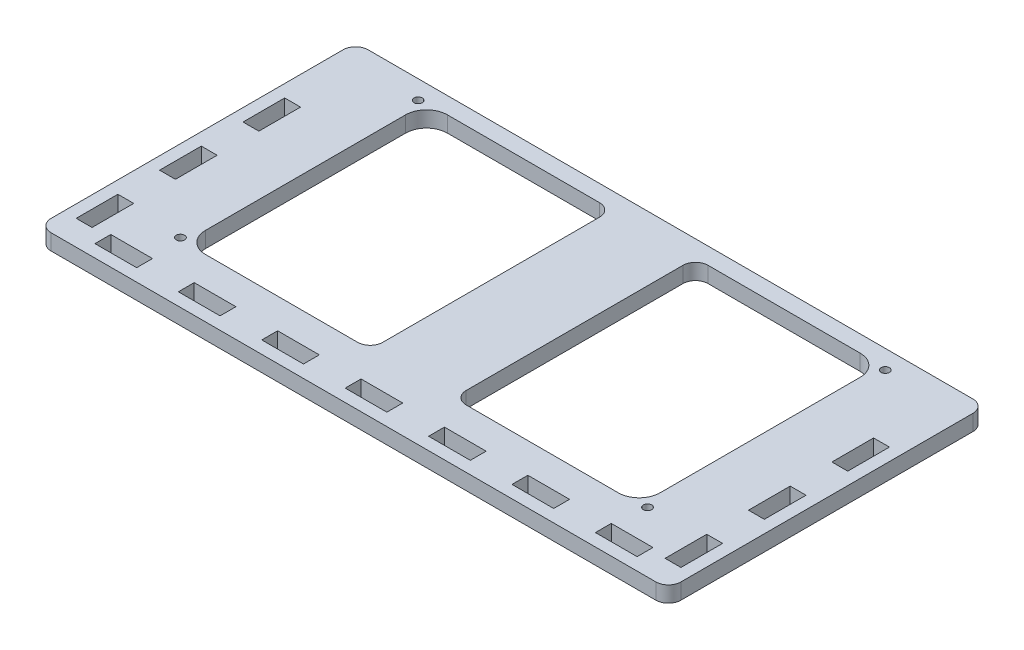
from build123d import *

# Parameters (mm, degrees)
SKETCH1_W           = 121
SKETCH1_H           = 66
BOSS_EXTRUDE1_DEPTH = 3.8
SKETCH2_W           = 109
SKETCH2_H           = 58
CUT_EXTRUDE1_DEPTH  = 4.8
FILLET1_R           = 5
SKETCH3_W           = 20
SKETCH3_H           = 58
BOSS_EXTRUDE2_DEPTH = 3.8
FILLET2_R           = 3
SKETCH4_R           = 1
CUT_EXTRUDE2_DEPTH  = 4.8
BOSS_EXTRUDE3_DEPTH = 3.8
FILLET3_R           = 3
SKETCH6_W           = 3.8
SKETCH6_H           = 10
SKETCH6_W_2         = 10
SKETCH6_H_2         = 3.8
CUT_EXTRUDE3_DEPTH  = 4.8


with BuildPart() as part:
    # Sketch1 → Boss-Extrude1 (new body)
    with BuildSketch(Plane(origin=(0, 0, 0), x_dir=(1, 0, 0), z_dir=(0, 1, 0))):
        with Locations((60.5, -33)):
            Rectangle(SKETCH1_W, SKETCH1_H)
    extrude(amount=BOSS_EXTRUDE1_DEPTH)

    # Sketch2 → Cut-Extrude1 (cut, through all)
    with BuildSketch(Plane(origin=(0, 3.8, 0), x_dir=(1, 0, 0), z_dir=(0, 1, 0))):
        with Locations((60.5, -33)):
            Rectangle(SKETCH2_W, SKETCH2_H)
    extrude(amount=-CUT_EXTRUDE1_DEPTH, mode=Mode.SUBTRACT)

    # Fillet1
    fillet1_edges = [part.edges().sort_by_distance(p)[0] for p in [
        (115, 1.9, 4),
        (115, 1.9, 62),
        (6, 1.9, 62),
        (6, 1.9, 4),
    ]]
    fillet(fillet1_edges, radius=FILLET1_R)

    # Sketch3 → Boss-Extrude2 (add, through all)
    with BuildSketch(Plane(origin=(0, 3.8, 0), x_dir=(1, 0, 0), z_dir=(0, 1, 0))):
        with Locations((60.5, -33)):
            Rectangle(SKETCH3_W, SKETCH3_H)
    extrude(amount=-BOSS_EXTRUDE2_DEPTH)

    # Fillet2
    fillet2_edges = [part.edges().sort_by_distance(p)[0] for p in [
        (70.5, 1.9, 4),
        (70.5, 1.9, 62),
        (50.5, 1.9, 62),
        (50.5, 1.9, 4),
    ]]
    fillet(fillet2_edges, radius=FILLET2_R)

    # Sketch4 → Cut-Extrude2 (cut, through all)
    with BuildSketch(Plane(origin=(0, 3.8, 0), x_dir=(1, 0, 0), z_dir=(0, 1, 0))):
        with Locations((116.5, -61.5)):
            Circle(SKETCH4_R)
        with Locations((116.5, -4.5)):
            Circle(SKETCH4_R)
        with Locations((4.5, -4.5)):
            Circle(SKETCH4_R)
        with Locations((4.5, -61.5)):
            Circle(SKETCH4_R)
    extrude(amount=-CUT_EXTRUDE2_DEPTH, mode=Mode.SUBTRACT)

    # Sketch5 → Boss-Extrude3 (add, through all)
    with BuildSketch(Plane(origin=(0, 3.8, 0), x_dir=(1, 0, 0), z_dir=(0, 1, 0))):
        Polygon((0, 0), (-15, 0), (-15, -76), (136, -76), (136, 0), (121, 0), (121, -66), (0, -66), align=None)
    extrude(amount=-BOSS_EXTRUDE3_DEPTH)

    # Fillet3
    fillet3_edges = [part.edges().sort_by_distance(p)[0] for p in [
        (136, 1.9, 0),
        (136, 1.9, 76),
        (-15, 1.9, 76),
        (-15, 1.9, 0),
    ]]
    fillet(fillet3_edges, radius=FILLET3_R)

    # Sketch6 → Cut-Extrude3 (cut, through all)
    with BuildSketch(Plane.XZ):
        with Locations((131.1, 25)):
            Rectangle(SKETCH6_W, SKETCH6_H)
        with Locations((131.1, 45)):
            Rectangle(SKETCH6_W, SKETCH6_H)
        with Locations((131.1, 65)):
            Rectangle(SKETCH6_W, SKETCH6_H)
        with Locations((120.5, 71.1)):
            Rectangle(SKETCH6_W_2, SKETCH6_H_2)
        with Locations((100.5, 71.1)):
            Rectangle(SKETCH6_W_2, SKETCH6_H_2)
        with Locations((80.5, 71.1)):
            Rectangle(SKETCH6_W_2, SKETCH6_H_2)
        with Locations((60.5, 71.1)):
            Rectangle(SKETCH6_W_2, SKETCH6_H_2)
        with Locations((40.5, 71.1)):
            Rectangle(SKETCH6_W_2, SKETCH6_H_2)
        with Locations((20.5, 71.1)):
            Rectangle(SKETCH6_W_2, SKETCH6_H_2)
        with Locations((0.5, 71.1)):
            Rectangle(SKETCH6_W_2, SKETCH6_H_2)
        with Locations((-10.1, 65)):
            Rectangle(SKETCH6_W, SKETCH6_H)
        with Locations((-10.1, 45)):
            Rectangle(SKETCH6_W, SKETCH6_H)
        with Locations((-10.1, 25)):
            Rectangle(SKETCH6_W, SKETCH6_H)
    extrude(amount=-CUT_EXTRUDE3_DEPTH, mode=Mode.SUBTRACT)


solid = part.part
